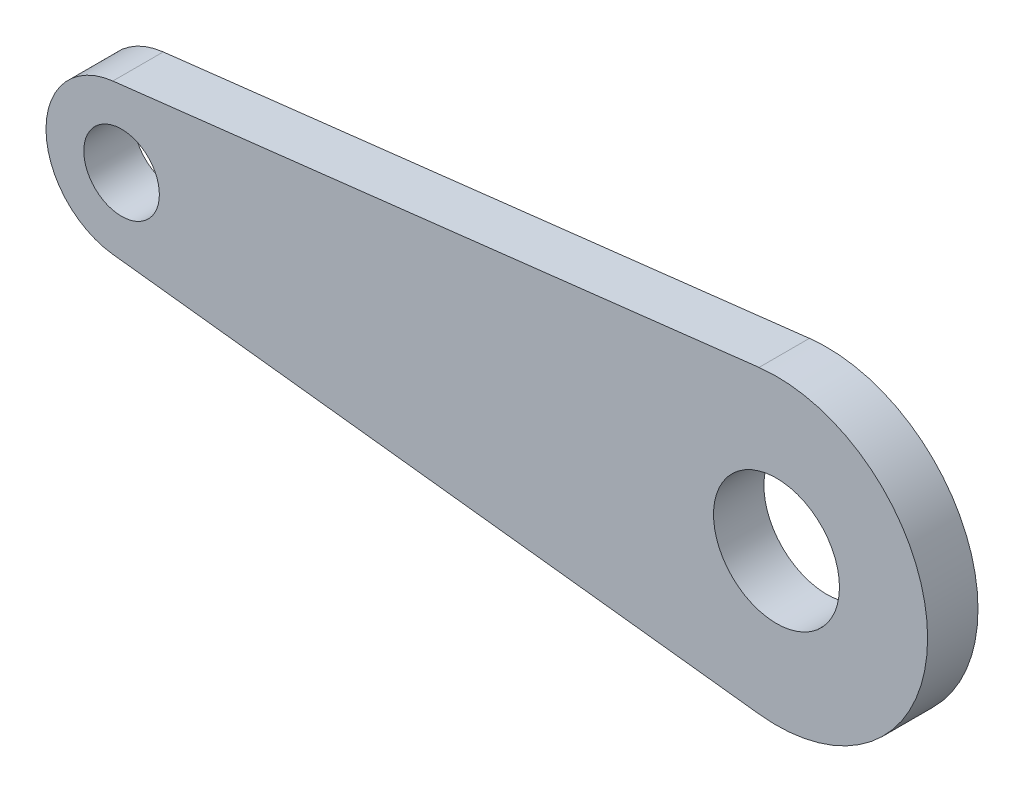
from build123d import *

# Parameters (mm, degrees)
SKICA2_R                = 7.5
SKICA2_R_2              = 12.5
P_IDAT_VYSUNUT_M1_DEPTH = 10


with BuildPart() as part:
    # Skica2 → Přidat vysunutím1 (new body)
    with BuildSketch(Plane.XY):
        with BuildLine():
            Line((-1.730769231, 14.89981335), (126.538461538, 29.7996267))
            ThreePointArc((126.538461538, 29.7996267), (160, 0), (126.538461538, -29.7996267))
            Line((126.538461538, -29.7996267), (-1.730769231, -14.89981335))
            ThreePointArc((-1.730769231, -14.89981335), (-15, 0), (-1.730769231, 14.89981335))
        make_face()
        Circle(SKICA2_R, mode=Mode.SUBTRACT)
        with Locations((130, 0)):
            Circle(SKICA2_R_2, mode=Mode.SUBTRACT)
    extrude(amount=P_IDAT_VYSUNUT_M1_DEPTH)


solid = part.part
